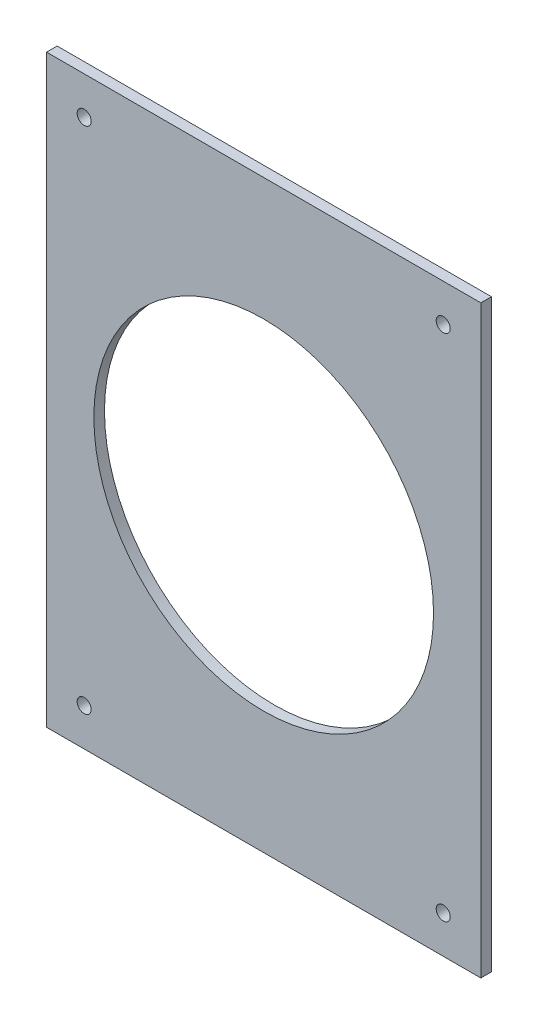
from build123d import *

# Parameters (mm, degrees)
SKETCH1_W                = 259.8
SKETCH1_H                = 349.8
SKETCH1_R                = 101.6
BOSS_EXTRUDE1_DEPTH      = 6.35
M8_CLEARANCE_HOLE1_D     = 8.4
M8_CLEARANCE_HOLE1_DEPTH = 76.2
M8_CLEARANCE_HOLE1_TIP   = 2.5236146


with BuildPart() as part:
    # Sketch1 → Boss-Extrude1 (new body)
    with BuildSketch(Plane.XY):
        with Locations((-129.9, 174.9)):
            Rectangle(SKETCH1_W, SKETCH1_H)
        with Locations((-129.9, 174.9)):
            Circle(SKETCH1_R, mode=Mode.SUBTRACT)
    extrude(amount=BOSS_EXTRUDE1_DEPTH)

    # M8 Clearance Hole1
    with Locations(Plane.XY.offset(6.35)):
        with Locations((-237.3, 327.3), (-22.5, 327.3), (-22.5, 22.5), (-237.3, 22.5)):
            Hole(M8_CLEARANCE_HOLE1_D / 2, depth=M8_CLEARANCE_HOLE1_DEPTH)
            with Locations((0, 0, -(M8_CLEARANCE_HOLE1_DEPTH + M8_CLEARANCE_HOLE1_TIP / 2))):  # 118° drill point
                Cone(0, M8_CLEARANCE_HOLE1_D / 2, M8_CLEARANCE_HOLE1_TIP, mode=Mode.SUBTRACT)


solid = part.part
